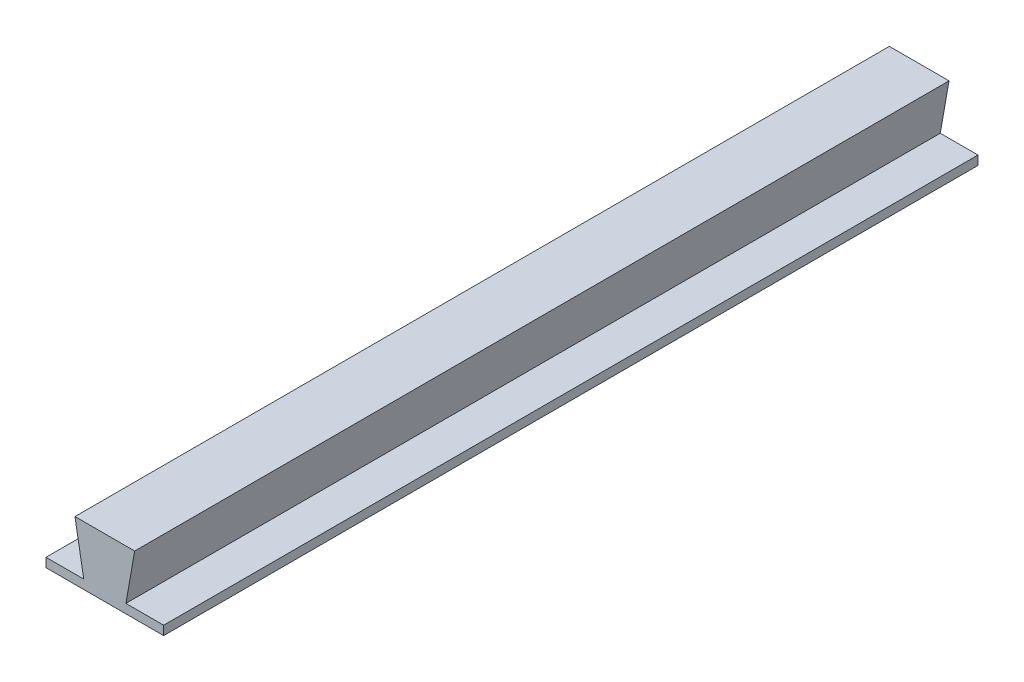
from build123d import *

# Parameters (mm, degrees)
BOSS_EXTRUDE1_DEPTH = 180
SKETCH2_W           = 26
SKETCH2_H           = 180
BOSS_EXTRUDE2_DEPTH = 2


with BuildPart() as part:
    # Sketch1 → Boss-Extrude1 (new body)
    with BuildSketch(Plane.XY):
        Polygon((-6.6, 11), (-4.660403212, 0), (0, 0), (0, 11), align=None)
        Polygon((0, 11), (0, 0), (4.660403212, 0), (6.6, 11), align=None)
    extrude(amount=BOSS_EXTRUDE1_DEPTH)

    # Sketch2 → Boss-Extrude2 (add)
    with BuildSketch(Plane.XZ):
        with Locations((0, 90)):
            Rectangle(SKETCH2_W, SKETCH2_H)
    extrude(amount=BOSS_EXTRUDE2_DEPTH)


solid = part.part
